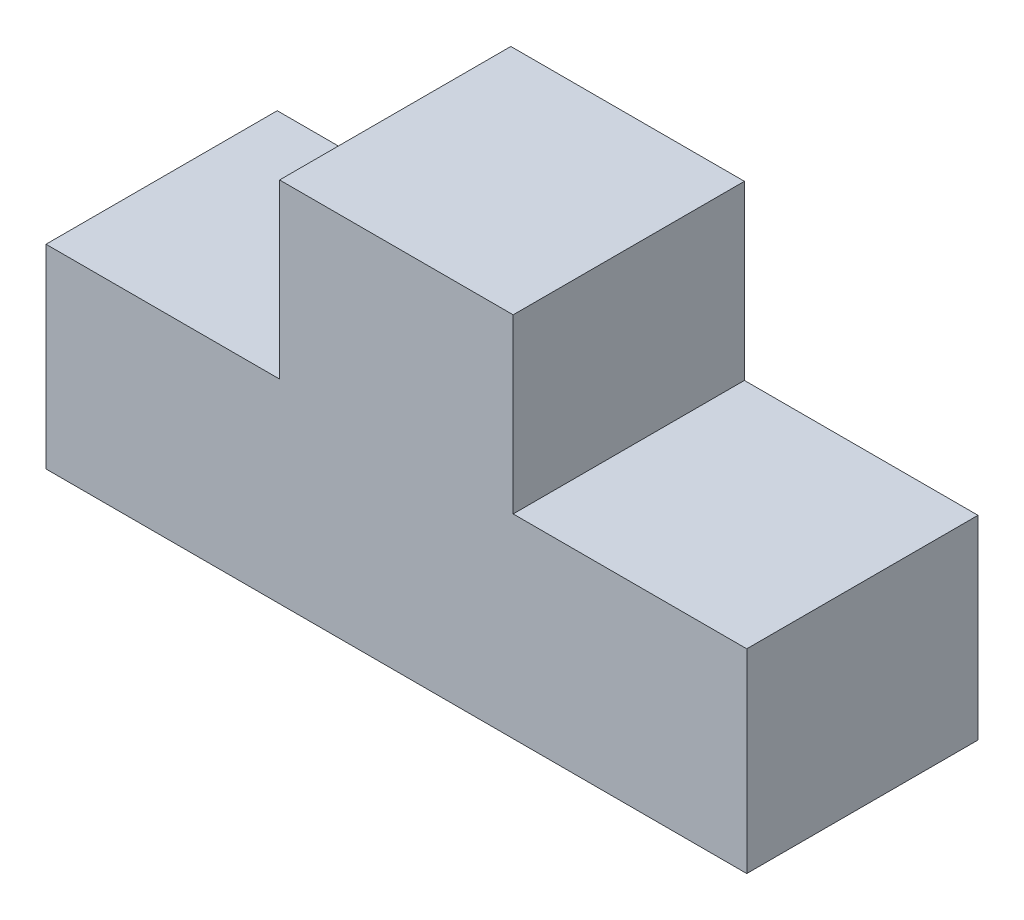
from build123d import *

# Parameters (mm, degrees)
BOSS_EXTRUDE1_DEPTH = 754.38


with BuildPart() as part:
    # Sketch1 → Boss-Extrude1 (new body)
    with BuildSketch(Plane.XY):
        Polygon((0, 0), (2286, 0), (2286, 635), (1524, 635), (1524, 1197.585726249), (762, 1197.585726249), (762, 635), (0, 635), align=None)
    extrude(amount=BOSS_EXTRUDE1_DEPTH)


solid = part.part
